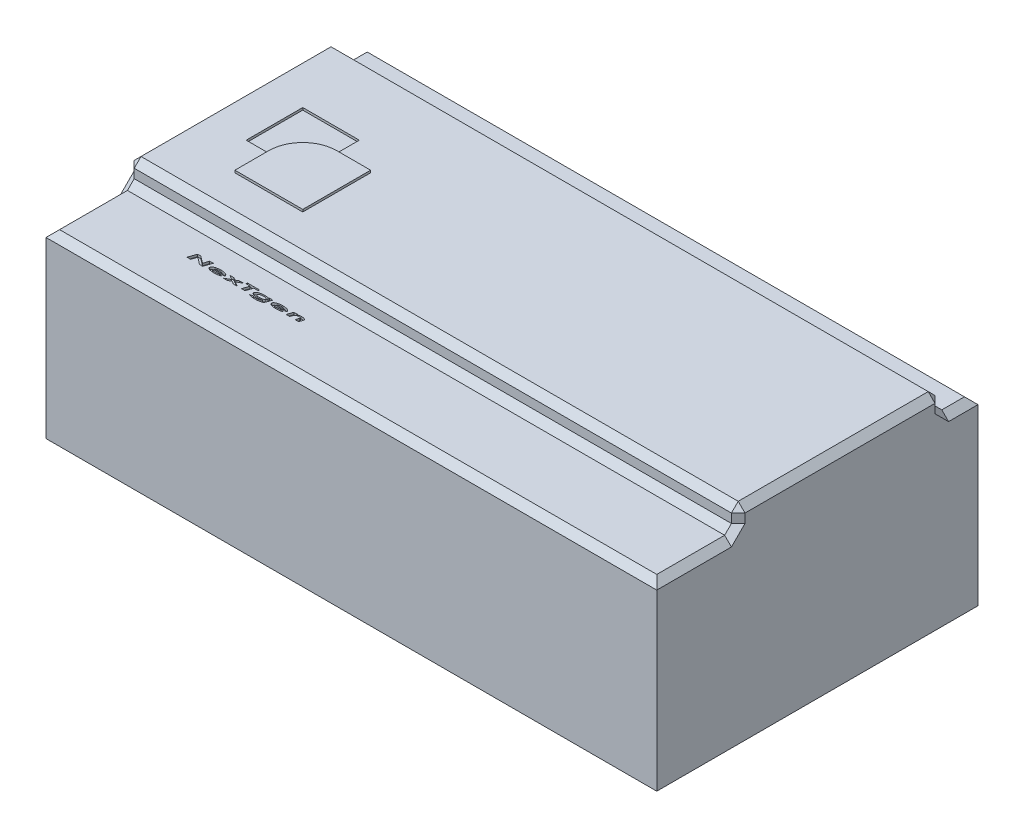
from build123d import *

# Parameters (mm, degrees)
SKETCH1_W           = 270
SKETCH1_H           = 142
BOSS_EXTRUDE1_DEPTH = 80
BOSS_EXTRUDE2_DEPTH = 10
SKETCH6_R           = 5
BOSS_EXTRUDE5_DEPTH = 2
CUT_EXTRUDE2_DEPTH  = 1
CHAMFER1_SIZE       = 3
SKETCH8_W           = 25
SKETCH8_H           = 25
CUT_EXTRUDE3_DEPTH  = 1
BOSS_EXTRUDE6_DEPTH = 1


with BuildPart() as part:
    # Sketch1 → Boss-Extrude1 (new body)
    with BuildSketch(Plane(origin=(0, 0, 0), x_dir=(1, 0, 0), z_dir=(0, 1, 0))):
        Rectangle(SKETCH1_W, SKETCH1_H)
    extrude(amount=BOSS_EXTRUDE1_DEPTH)

    # Sketch2 → Boss-Extrude2 (add)
    with BuildSketch(Plane(origin=(0, 80, 0), x_dir=(1, 0, 0), z_dir=(0, 1, 0))):
        Polygon((-135, -35), (135, -35), (135, 35), (135, 55), (-135, 55), (-135, 35), align=None)
    extrude(amount=BOSS_EXTRUDE2_DEPTH)

    # Sketch6 → Boss-Extrude5 (add)
    with BuildSketch(Plane.ZY.offset(135)):
        with Locations((-24.42759898, 39.904944775)):
            Circle(SKETCH6_R)
        with Locations((22.518514868, 39.904944775)):
            Circle(SKETCH6_R)
    extrude(amount=BOSS_EXTRUDE5_DEPTH)

    # Sketch7 → Cut-Extrude2 (cut)
    with BuildSketch(Plane(origin=(0, 80, 0), x_dir=(1, 0, 0), z_dir=(0, 1, 0))):
        Polygon((-92.091078078, -46.905996593), (-90.65798513, -46.905996593), (-87.531683046, -49.285603965), (-86.742921027, -46.905996593), (-85.158385771, -46.905996593), (-86.315937854, -50.405996593), (-87.740617341, -50.405996593), (-90.875332886, -48.000447715), (-91.672508367, -50.405996593), (-93.257043623, -50.405996593), align=None)
        with BuildLine():
            Line((-79.745024392, -49.649486176), (-78.369423431, -49.931337138))
            add(Edge.make_bspline(
                [(-78.369423431, -49.931337138), (-78.409202544, -49.951131626), (-78.490887738, -49.991779004), (-78.620489264, -50.046733239), (-78.75894812, -50.099611858), (-78.907502369, -50.147180504), (-79.064552353, -50.194069583), (-79.231507877, -50.236197272), (-79.407660389, -50.276513683), (-79.592715412, -50.312360782), (-79.784770026, -50.345544444), (-79.982868277, -50.373312761), (-80.186015616, -50.397118824), (-80.394537686, -50.416744416), (-80.608203023, -50.432036667), (-80.82698489, -50.44340482), (-81.050943252, -50.449643952), (-81.20195185, -50.450456935), (-81.278377758, -50.450868388)],
                knots=[0, 0, 0, 0, 0.000133268, 0.000273663, 0.00042211, 0.000577756, 0.000741483, 0.000913743, 0.001094206, 0.001283546, 0.00147915, 0.001678846, 0.001883564, 0.00209272, 0.002307118, 0.002526155, 0.002749902, 0.002979179, 0.002979179, 0.002979179, 0.002979179], degree=3))
            add(Edge.make_bspline(
                [(-81.278377758, -50.450868388), (-81.337974541, -50.450541944), (-81.455775772, -50.449896684), (-81.630148049, -50.4464952), (-81.799852761, -50.440287263), (-81.964609253, -50.430927446), (-82.124537545, -50.420104696), (-82.279450786, -50.405686254), (-82.429663821, -50.390281426), (-82.574858091, -50.369805897), (-82.715744677, -50.349449689), (-82.851792969, -50.325485108), (-82.9829899, -50.29900426), (-83.109133066, -50.269340976), (-83.230628496, -50.238119267), (-83.346948873, -50.203558169), (-83.458819882, -50.167185085), (-83.565539345, -50.128307741), (-83.666539882, -50.086553099), (-83.761802625, -50.044662502), (-83.849778325, -49.99905679), (-83.931726695, -49.953292951), (-84.007262531, -49.905525461), (-84.07588346, -49.855619582), (-84.138775404, -49.804765171), (-84.194142294, -49.751117885), (-84.243557252, -49.696636761), (-84.286035895, -49.640071345), (-84.321860751, -49.581808478), (-84.351436792, -49.521969514), (-84.375110615, -49.460620897), (-84.3908876, -49.397237088), (-84.401198288, -49.332213221), (-84.402579424, -49.288214283), (-84.403277597, -49.265972554)],
                knots=[0, 0, 0, 0, 0.000178792, 0.000353406, 0.000523195, 0.00068821, 0.000848459, 0.00100404, 0.001154945, 0.001301398, 0.001443885, 0.001581976, 0.001715765, 0.001845357, 0.001970687, 0.002092038, 0.002209327, 0.002323558, 0.002432665, 0.00253717, 0.00263563, 0.002729812, 0.0028187, 0.002903548, 0.002984253, 0.003061111, 0.003134592, 0.003204704, 0.003273005, 0.003339479, 0.003404717, 0.003469846, 0.003535092, 0.00360179, 0.00360179, 0.00360179, 0.00360179], degree=3))
            add(Edge.make_bspline(
                [(-84.403277597, -49.265972554), (-84.40238153, -49.240695045), (-84.400587942, -49.190099009), (-84.388772095, -49.114877496), (-84.367152557, -49.041520803), (-84.338179949, -48.969732725), (-84.301887572, -48.898998878), (-84.255312801, -48.831027039), (-84.202043311, -48.763667702), (-84.140905742, -48.697241528), (-84.070265228, -48.633893347), (-83.992010337, -48.571267628), (-83.906026442, -48.509718211), (-83.81154152, -48.450072916), (-83.708982427, -48.391993516), (-83.598255738, -48.335061227), (-83.478717848, -48.280966525), (-83.30829265, -48.208018171), (-83.082466629, -48.125192798), (-82.798958296, -48.038984708), (-82.501796204, -47.96652388), (-82.191435237, -47.905881053), (-81.867250401, -47.860106092), (-81.52943408, -47.827711331), (-81.178155548, -47.806504472), (-80.939300047, -47.804468596), (-80.817740739, -47.80343249)],
                knots=[0, 0, 0, 0, 7.5838e-05, 0.000151799, 0.000227689, 0.000304764, 0.000383789, 0.000465655, 0.000551502, 0.000641303, 0.0007361, 0.000835852, 0.000941888, 0.001053146, 0.001170894, 0.001295381, 0.001426518, 0.001564428, 0.001851477, 0.002147567, 0.002452974, 0.002768681, 0.003095888, 0.003434733, 0.003786583, 0.004151221, 0.004151221, 0.004151221, 0.004151221], degree=3))
            add(Edge.make_bspline(
                [(-80.817740739, -47.80343249), (-80.744119479, -47.804096089), (-80.598948014, -47.805404617), (-80.384300342, -47.812019237), (-80.175830572, -47.825170262), (-79.973278306, -47.841349902), (-79.776906864, -47.863948714), (-79.586896696, -47.891463782), (-79.402701703, -47.922514029), (-79.225362259, -47.959927616), (-79.055334137, -48.000559499), (-78.894501057, -48.04703577), (-78.742734827, -48.097628342), (-78.599779885, -48.151497017), (-78.466737317, -48.211783907), (-78.342282109, -48.275150843), (-78.227247441, -48.34375806), (-78.122270624, -48.416624599), (-78.027467162, -48.49162328), (-77.945418772, -48.569559534), (-77.8749076, -48.648252817), (-77.817514929, -48.729297318), (-77.772840372, -48.812416707), (-77.740967263, -48.897254878), (-77.721025154, -48.983666422), (-77.718593124, -49.041978068), (-77.717380162, -49.071060695)],
                knots=[0, 0, 0, 0, 0.000220871, 0.000435529, 0.000644144, 0.000847466, 0.001045058, 0.001237019, 0.001423403, 0.001605324, 0.001780646, 0.001947738, 0.002107372, 0.0022605, 0.002405796, 0.002545335, 0.002679284, 0.002807258, 0.002928471, 0.003041545, 0.00314635, 0.003244972, 0.003338758, 0.003428613, 0.00351622, 0.003603388, 0.003603388, 0.003603388, 0.003603388], degree=3))
            add(Edge.make_bspline(
                [(-77.717380162, -49.071060695), (-77.718046964, -49.090279235), (-77.719439743, -49.13042182), (-77.732013048, -49.19270385), (-77.749708112, -49.259980105), (-77.767165868, -49.305384124), (-77.776274392, -49.329073516)],
                knots=[0, 0, 0, 0, 5.7599e-05, 0.000120309, 0.000190042, 0.000266116, 0.000266116, 0.000266116, 0.000266116], degree=3))
            Line((-77.776274392, -49.329073516), (-82.877636572, -49.329073516))
            add(Edge.make_bspline(
                [(-82.877636572, -49.329073516), (-82.874506134, -49.349386996), (-82.868238749, -49.390056205), (-82.84323482, -49.448128194), (-82.805681881, -49.501989653), (-82.756431297, -49.552734561), (-82.695248039, -49.600584324), (-82.621943292, -49.645137465), (-82.536444276, -49.686512582), (-82.439105923, -49.723595655), (-82.331337612, -49.758113131), (-82.21314915, -49.78701312), (-82.085249847, -49.812505489), (-81.947556679, -49.832114438), (-81.800287888, -49.848621049), (-81.643317564, -49.859221372), (-81.476399512, -49.866635088), (-81.361820272, -49.867229485), (-81.302917021, -49.867535054)],
                knots=[0, 0, 0, 0, 6.1463e-05, 0.000123054, 0.000187618, 0.000257538, 0.000334406, 0.000420023, 0.000514406, 0.000618958, 0.000732265, 0.000853678, 0.000983755, 0.001123364, 0.001270784, 0.001428235, 0.001595249, 0.001771944, 0.001771944, 0.001771944, 0.001771944], degree=3))
            add(Edge.make_bspline(
                [(-81.302917021, -49.867535054), (-81.23069267, -49.86679523), (-81.088280467, -49.865336442), (-80.877761485, -49.855781182), (-80.673656764, -49.837971793), (-80.475826224, -49.814184307), (-80.283858588, -49.784521871), (-80.098533327, -49.746285123), (-79.918868186, -49.702718572), (-79.802591951, -49.667113835), (-79.745024392, -49.649486176)],
                knots=[0, 0, 0, 0, 0.000216675, 0.00042724, 0.000632018, 0.000831167, 0.001024933, 0.001214548, 0.00139871, 0.001579292, 0.001579292, 0.001579292, 0.001579292], degree=3))
        make_face()
        with BuildLine():
            add(Edge.make_bspline(
                [(-79.377636572, -48.880355567), (-79.392871526, -48.860365347), (-79.423847673, -48.819720655), (-79.479035494, -48.76458292), (-79.541419528, -48.713322198), (-79.610038836, -48.664803149), (-79.686249908, -48.620399708), (-79.770191003, -48.581038092), (-79.860645491, -48.543311617), (-79.958657787, -48.51121915), (-80.062385162, -48.481446493), (-80.172032621, -48.456617795), (-80.286798978, -48.434699041), (-80.40687022, -48.417552109), (-80.531922636, -48.403284099), (-80.66243123, -48.393640662), (-80.798294423, -48.388113117), (-80.890652303, -48.387220087), (-80.937632565, -48.386765824)],
                knots=[0, 0, 0, 0, 7.5334e-05, 0.000153171, 0.000233335, 0.000317368, 0.00040503, 0.000497541, 0.000595322, 0.000698863, 0.000806726, 0.000918976, 0.001035996, 0.001157162, 0.001282747, 0.001413525, 0.001549658, 0.001690599, 0.001690599, 0.001690599, 0.001690599], degree=3))
            add(Edge.make_bspline(
                [(-80.937632565, -48.386765824), (-80.98437682, -48.387252557), (-81.076963429, -48.388216634), (-81.214041412, -48.393381602), (-81.34771165, -48.404474026), (-81.477810784, -48.417925016), (-81.604441559, -48.436675119), (-81.727903272, -48.45772379), (-81.847686502, -48.484875863), (-81.963572236, -48.514548201), (-82.074278557, -48.54808118), (-82.178697153, -48.585096345), (-82.276293064, -48.625378143), (-82.36642828, -48.670287791), (-82.450673891, -48.716440536), (-82.527389782, -48.767308396), (-82.597479593, -48.821221259), (-82.63956042, -48.860839973), (-82.660288815, -48.880355567)],
                knots=[0, 0, 0, 0, 0.00014024, 0.000277774, 0.000411402, 0.000542562, 0.000670074, 0.000795371, 0.000918188, 0.001038415, 0.001154192, 0.001265071, 0.001370671, 0.001470695, 0.001567056, 0.001658645, 0.001746579, 0.001831944, 0.001831944, 0.001831944, 0.001831944], degree=3))
            Line((-82.660288815, -48.880355567), (-79.377636572, -48.880355567))
        make_face(mode=Mode.SUBTRACT)
        Polygon((-76.779980322, -47.848304285), (-75.038393783, -47.848304285), (-73.932724713, -48.568356368), (-72.606903399, -47.848304285), (-70.762251956, -47.848304285), (-73.093481924, -49.113829125), (-71.108606123, -50.405996593), (-72.84949154, -50.405996593), (-74.042800835, -49.629153644), (-75.473790418, -50.405996593), (-77.31844186, -50.405996593), (-74.882043623, -49.083680888), align=None)
        Polygon((-69.954559649, -46.905996593), (-64.659687854, -46.905996593), (-64.847588495, -47.489329926), (-66.653678239, -47.489329926), (-67.60720388, -50.405996593), (-69.191739136, -50.405996593), (-68.238914617, -47.489329926), (-70.15437936, -47.489329926), align=None)
        with BuildLine():
            Line((-59.448950674, -47.848304285), (-57.863013174, -47.848304285))
            Line((-57.863013174, -47.848304285), (-58.564836091, -49.933440503))
            add(Edge.make_bspline(
                [(-58.564836091, -49.933440503), (-58.582062239, -49.980296752), (-58.615163506, -50.070334361), (-58.667739527, -50.198387651), (-58.7209128, -50.313894578), (-58.773837411, -50.417825099), (-58.828541197, -50.50856022), (-58.882247707, -50.587858676), (-58.936696899, -50.654877461), (-58.976456649, -50.691976678), (-58.995324873, -50.70958233)],
                knots=[0, 0, 0, 0, 0.00014976, 0.000287774, 0.000415141, 0.000531165, 0.000637459, 0.000732752, 0.000818392, 0.000895738, 0.000895738, 0.000895738, 0.000895738], degree=3))
            add(Edge.make_bspline(
                [(-58.995324873, -50.70958233), (-59.026190033, -50.734282107), (-59.090544672, -50.785781767), (-59.20056253, -50.85361472), (-59.324382696, -50.919733452), (-59.463199005, -50.982274817), (-59.616679924, -51.042041663), (-59.784974536, -51.097437566), (-59.967824607, -51.150801183), (-60.16483379, -51.201128401), (-60.375913702, -51.246832729), (-60.600553365, -51.285593871), (-60.838081582, -51.319274294), (-61.088756315, -51.346474129), (-61.35251813, -51.367133394), (-61.629288064, -51.382563555), (-61.919172683, -51.39179648), (-62.1167123, -51.39270944), (-62.217680642, -51.39317608)],
                knots=[0, 0, 0, 0, 0.000118498, 0.000247071, 0.000386966, 0.000539456, 0.000703508, 0.000880879, 0.001070799, 0.001274858, 0.00149076, 0.001718529, 0.00195858, 0.00221037, 0.002474829, 0.002752201, 0.003041908, 0.003344806, 0.003344806, 0.003344806, 0.003344806], degree=3))
            add(Edge.make_bspline(
                [(-62.217680642, -51.39317608), (-62.302056621, -51.392924202), (-62.467807923, -51.392429405), (-62.712292342, -51.384023686), (-62.948420117, -51.372599243), (-63.176579365, -51.355683872), (-63.396375246, -51.334275425), (-63.60786927, -51.307248767), (-63.811236682, -51.277123167), (-64.005374699, -51.240383459), (-64.189359642, -51.200608561), (-64.362105949, -51.158254579), (-64.522385706, -51.11188104), (-64.671000989, -51.063583637), (-64.807621438, -51.012885835), (-64.932080727, -50.958746403), (-65.044941159, -50.902627388), (-65.11382081, -50.860340528), (-65.146967501, -50.839990984)],
                knots=[0, 0, 0, 0, 0.000253114, 0.000497226, 0.000733804, 0.000962289, 0.001183512, 0.001396225, 0.001601877, 0.001800169, 0.001988845, 0.002166545, 0.002333637, 0.002489283, 0.002635268, 0.002770601, 0.002896336, 0.003012971, 0.003012971, 0.003012971, 0.003012971], degree=3))
            Line((-65.146967501, -50.839990984), (-63.778377758, -50.560944509))
            add(Edge.make_bspline(
                [(-63.778377758, -50.560944509), (-63.725334029, -50.581048825), (-63.616674882, -50.622232164), (-63.444958711, -50.671868416), (-63.261992179, -50.714843785), (-63.067434556, -50.749383), (-62.861110055, -50.776714848), (-62.643344528, -50.796210764), (-62.413874568, -50.807172983), (-62.257188613, -50.808939074), (-62.177015578, -50.809842747)],
                knots=[0, 0, 0, 0, 0.000170119, 0.000348485, 0.000535726, 0.000733766, 0.000941006, 0.001159937, 0.001389478, 0.00163, 0.00163, 0.00163, 0.00163], degree=3))
            add(Edge.make_bspline(
                [(-62.177015578, -50.809842747), (-62.130038622, -50.809518572), (-62.037707912, -50.808881424), (-61.901654524, -50.805495714), (-61.770270034, -50.799255349), (-61.643831678, -50.790006526), (-61.522224458, -50.779044799), (-61.405555385, -50.765001804), (-61.293831738, -50.748195541), (-61.18698368, -50.72927888), (-61.085488607, -50.70834762), (-60.989537408, -50.685474065), (-60.899433553, -50.659877713), (-60.8149221, -50.633549186), (-60.736125352, -50.605750052), (-60.663442401, -50.575322093), (-60.59644493, -50.543382249), (-60.534705451, -50.509490393), (-60.477618872, -50.473011525), (-60.426038532, -50.431298587), (-60.377662564, -50.386335159), (-60.334424536, -50.336590784), (-60.295665369, -50.282602747), (-60.260362223, -50.225264008), (-60.23010177, -50.1631653), (-60.21375887, -50.119614862), (-60.205461091, -50.097503003)],
                knots=[0, 0, 0, 0, 0.000140932, 0.000276995, 0.000408257, 0.000535487, 0.000657298, 0.000774526, 0.000887961, 0.0009962, 0.001100015, 0.001198816, 0.001292042, 0.001380963, 0.001464346, 0.001542602, 0.001617238, 0.001686903, 0.001753801, 0.001820156, 0.001885627, 0.001951715, 0.00201749, 0.002084827, 0.002153498, 0.002224325, 0.002224325, 0.002224325, 0.002224325], degree=3))
            add(Edge.make_bspline(
                [(-60.205461091, -50.097503003), (-60.278599581, -50.122367272), (-60.426316056, -50.172585183), (-60.654611684, -50.233961272), (-60.889568182, -50.287624643), (-61.131975125, -50.330949144), (-61.381579719, -50.364570221), (-61.638440148, -50.387927264), (-61.902455059, -50.403329496), (-62.080939815, -50.405099466), (-62.171406604, -50.405996593)],
                knots=[0, 0, 0, 0, 0.000231694, 0.000467948, 0.000708792, 0.000954554, 0.001206412, 0.001464128, 0.00172816, 0.001999539, 0.001999539, 0.001999539, 0.001999539], degree=3))
            add(Edge.make_bspline(
                [(-62.171406604, -50.405996593), (-62.234514281, -50.405651533), (-62.359601234, -50.404967584), (-62.545466858, -50.397710893), (-62.72760864, -50.385997787), (-62.906186777, -50.36892695), (-63.081057683, -50.347959579), (-63.252595777, -50.32316811), (-63.420084022, -50.291842429), (-63.58338146, -50.257248001), (-63.740424262, -50.218417794), (-63.889447097, -50.174966568), (-64.029721727, -50.127249456), (-64.161718901, -50.076171389), (-64.285170505, -50.021710652), (-64.40000789, -49.963455354), (-64.506110128, -49.901301735), (-64.602682556, -49.8347323), (-64.689481335, -49.765975949), (-64.765187679, -49.694833748), (-64.829692049, -49.621998697), (-64.881771697, -49.546481303), (-64.923459076, -49.469661375), (-64.952157649, -49.390233771), (-64.970795591, -49.308904543), (-64.972790494, -49.253686211), (-64.973790418, -49.226008612)],
                knots=[0, 0, 0, 0, 0.000189315, 0.000375244, 0.000557925, 0.000736803, 0.000913341, 0.001086267, 0.001256651, 0.001424417, 0.001586982, 0.001741846, 0.001889954, 0.002031353, 0.002166325, 0.002294571, 0.002417462, 0.002534926, 0.002646175, 0.002749338, 0.002846227, 0.00293744, 0.003024008, 0.00310763, 0.003190142, 0.003273065, 0.003273065, 0.003273065, 0.003273065], degree=3))
            add(Edge.make_bspline(
                [(-64.973790418, -49.226008612), (-64.972237168, -49.19479739), (-64.969114399, -49.132048072), (-64.945594311, -49.038956569), (-64.906979988, -48.947871883), (-64.853899378, -48.858099292), (-64.784483659, -48.770815916), (-64.700886876, -48.684632252), (-64.601613129, -48.600640372), (-64.489071672, -48.517560975), (-64.363363826, -48.437295933), (-64.225316848, -48.362167371), (-64.077403848, -48.289381056), (-63.917726388, -48.222880066), (-63.748039744, -48.158522162), (-63.566930113, -48.100235253), (-63.375214048, -48.045395216), (-63.173992313, -47.995644111), (-62.966221114, -47.950128562), (-62.754589888, -47.910942216), (-62.540365862, -47.878152794), (-62.324148119, -47.850640368), (-62.105500866, -47.829807823), (-61.88482965, -47.814273794), (-61.661540248, -47.804885426), (-61.51189359, -47.803918694), (-61.436630963, -47.80343249)],
                knots=[0, 0, 0, 0, 9.3568e-05, 0.000188115, 0.000286164, 0.000389575, 0.000499954, 0.000619946, 0.000749227, 0.000889595, 0.001039354, 0.001196255, 0.001360877, 0.001533679, 0.00171495, 0.001905185, 0.002104251, 0.002313069, 0.002526915, 0.002742264, 0.00295863, 0.003176995, 0.003396056, 0.003617448, 0.003840591, 0.004066369, 0.004066369, 0.004066369, 0.004066369], degree=3))
            add(Edge.make_bspline(
                [(-61.436630963, -47.80343249), (-61.347334261, -47.804556474), (-61.172564307, -47.806756315), (-60.916737957, -47.822541022), (-60.673698373, -47.850884579), (-60.441452097, -47.888881065), (-60.21667188, -47.94157417), (-59.995705176, -48.008082133), (-59.776884439, -48.090050026), (-59.634819745, -48.155878562), (-59.563233527, -48.189049477)],
                knots=[0, 0, 0, 0, 0.000267887, 0.000524304, 0.000768508, 0.001001687, 0.001229918, 0.001460596, 0.001693565, 0.001930196, 0.001930196, 0.001930196, 0.001930196], degree=3))
            Line((-59.563233527, -48.189049477), (-59.448950674, -47.848304285))
        make_face()
        with BuildLine():
            add(Edge.make_bspline(
                [(-61.360208687, -48.386765824), (-61.430571603, -48.387341991), (-61.56858639, -48.388472127), (-61.771340256, -48.400193392), (-61.965774862, -48.417940396), (-62.151801721, -48.443799269), (-62.329149994, -48.477352851), (-62.498077632, -48.518141546), (-62.658850898, -48.565450174), (-62.809669067, -48.620227858), (-62.947007831, -48.68024145), (-63.068201363, -48.743608852), (-63.170346378, -48.811396661), (-63.254588691, -48.882354119), (-63.320665347, -48.957160363), (-63.367787328, -49.035952622), (-63.398321909, -49.118666264), (-63.40162598, -49.175742794), (-63.403277597, -49.204273836)],
                knots=[0, 0, 0, 0, 0.000211067, 0.000414001, 0.000609066, 0.000796665, 0.000977213, 0.001150326, 0.001317812, 0.001479724, 0.001631357, 0.001767168, 0.001889481, 0.001998381, 0.002096788, 0.002187331, 0.002272698, 0.002358022, 0.002358022, 0.002358022, 0.002358022], degree=3))
            add(Edge.make_bspline(
                [(-63.403277597, -49.204273836), (-63.401933155, -49.227339455), (-63.399272199, -49.27299152), (-63.377544848, -49.33933468), (-63.34277202, -49.401868118), (-63.292715238, -49.459685031), (-63.230338402, -49.514735008), (-63.153997348, -49.565664835), (-63.063835114, -49.612333685), (-62.961500732, -49.656137792), (-62.847216114, -49.694906025), (-62.723083521, -49.729014629), (-62.589735054, -49.758471343), (-62.447197303, -49.782144572), (-62.295553023, -49.799990962), (-62.134684207, -49.81343097), (-61.964413944, -49.820940967), (-61.847729078, -49.822079446), (-61.787892982, -49.822663259)],
                knots=[0, 0, 0, 0, 6.9067e-05, 0.000136699, 0.000207317, 0.000282455, 0.000364902, 0.000456298, 0.000556972, 0.000669103, 0.000789943, 0.000918709, 0.001055138, 0.001199448, 0.001351983, 0.001513092, 0.001683639, 0.001863148, 0.001863148, 0.001863148, 0.001863148], degree=3))
            add(Edge.make_bspline(
                [(-61.787892982, -49.822663259), (-61.69741367, -49.821505602), (-61.519989904, -49.819235514), (-61.259051343, -49.799808546), (-61.008581345, -49.768648776), (-60.807311204, -49.731785059), (-60.653652249, -49.696218695), (-60.545377586, -49.666703821), (-60.443098636, -49.634634456), (-60.346858757, -49.599723294), (-60.257196463, -49.561655848), (-60.173120026, -49.522172681), (-60.096168233, -49.47813035), (-60.024597375, -49.433408955), (-59.961105327, -49.385458539), (-59.904377423, -49.337693677), (-59.857320889, -49.287505225), (-59.818034795, -49.237194882), (-59.788467473, -49.185246035), (-59.765915023, -49.133075132), (-59.752951932, -49.079167718), (-59.751269537, -49.042845939), (-59.750433046, -49.024786657)],
                knots=[0, 0, 0, 0, 0.000271407, 0.000532212, 0.000784493, 0.001028311, 0.001145658, 0.001257574, 0.001364899, 0.00146715, 0.001564553, 0.001657063, 0.001745594, 0.001830395, 0.001910042, 0.001984113, 0.002052557, 0.002116082, 0.00217513, 0.002231382, 0.002286141, 0.002340291, 0.002340291, 0.002340291, 0.002340291], degree=3))
            add(Edge.make_bspline(
                [(-59.750433046, -49.024786657), (-59.751750066, -49.002180271), (-59.754374528, -48.957131894), (-59.776964647, -48.891366365), (-59.813428707, -48.829440765), (-59.863756779, -48.770241368), (-59.928522671, -48.71533325), (-60.006501598, -48.662377026), (-60.098907622, -48.613143693), (-60.204183713, -48.56670112), (-60.320419387, -48.524549883), (-60.445352582, -48.487195453), (-60.578536647, -48.456909972), (-60.719242248, -48.430576491), (-60.868424897, -48.411640337), (-61.025279201, -48.3965743), (-61.190214943, -48.388359851), (-61.30270849, -48.387305002), (-61.360208687, -48.386765824)],
                knots=[0, 0, 0, 0, 6.7672e-05, 0.000134852, 0.000206163, 0.000282289, 0.000366779, 0.000460123, 0.000564593, 0.000680416, 0.00080507, 0.000935284, 0.00107134, 0.001214633, 0.001364561, 0.001522301, 0.00168728, 0.001859778, 0.001859778, 0.001859778, 0.001859778], degree=3))
        make_face(mode=Mode.SUBTRACT)
        with BuildLine():
            Line((-52.373229521, -49.649486176), (-50.997628559, -49.931337138))
            add(Edge.make_bspline(
                [(-50.997628559, -49.931337138), (-51.037407672, -49.951131626), (-51.119092866, -49.991779004), (-51.248694392, -50.046733239), (-51.387153248, -50.099611858), (-51.535707497, -50.147180504), (-51.692757481, -50.194069583), (-51.859713006, -50.236197272), (-52.035865517, -50.276513683), (-52.22092054, -50.312360782), (-52.412975154, -50.345544444), (-52.611073405, -50.373312761), (-52.814220744, -50.397118824), (-53.022742814, -50.416744416), (-53.236408151, -50.432036667), (-53.455190018, -50.44340482), (-53.67914838, -50.449643952), (-53.830156978, -50.450456935), (-53.906582886, -50.450868388)],
                knots=[0, 0, 0, 0, 0.000133268, 0.000273663, 0.00042211, 0.000577756, 0.000741483, 0.000913743, 0.001094206, 0.001283546, 0.00147915, 0.001678846, 0.001883564, 0.00209272, 0.002307118, 0.002526155, 0.002749902, 0.002979179, 0.002979179, 0.002979179, 0.002979179], degree=3))
            add(Edge.make_bspline(
                [(-53.906582886, -50.450868388), (-53.966179669, -50.450541944), (-54.0839809, -50.449896684), (-54.258353177, -50.4464952), (-54.428057889, -50.440287263), (-54.592814381, -50.430927446), (-54.752742674, -50.420104696), (-54.907655914, -50.405686254), (-55.057868949, -50.390281426), (-55.203063219, -50.369805897), (-55.343949805, -50.349449689), (-55.479998097, -50.325485108), (-55.611195028, -50.29900426), (-55.737338194, -50.269340976), (-55.858833624, -50.238119267), (-55.975154002, -50.203558169), (-56.087025011, -50.167185085), (-56.193744474, -50.128307741), (-56.294745011, -50.086553099), (-56.390007753, -50.044662502), (-56.477983453, -49.99905679), (-56.559931823, -49.953292951), (-56.63546766, -49.905525461), (-56.704088588, -49.855619582), (-56.766980532, -49.804765171), (-56.822347422, -49.751117885), (-56.87176238, -49.696636761), (-56.914241024, -49.640071345), (-56.950065879, -49.581808478), (-56.97964192, -49.521969514), (-57.003315743, -49.460620897), (-57.019092728, -49.397237088), (-57.029403416, -49.332213221), (-57.030784553, -49.288214283), (-57.031482726, -49.265972554)],
                knots=[0, 0, 0, 0, 0.000178792, 0.000353406, 0.000523195, 0.00068821, 0.000848459, 0.00100404, 0.001154945, 0.001301398, 0.001443885, 0.001581976, 0.001715765, 0.001845357, 0.001970687, 0.002092038, 0.002209327, 0.002323558, 0.002432665, 0.00253717, 0.00263563, 0.002729812, 0.0028187, 0.002903548, 0.002984253, 0.003061111, 0.003134592, 0.003204704, 0.003273005, 0.003339479, 0.003404717, 0.003469846, 0.003535092, 0.00360179, 0.00360179, 0.00360179, 0.00360179], degree=3))
            add(Edge.make_bspline(
                [(-57.031482726, -49.265972554), (-57.030586659, -49.240695045), (-57.028793071, -49.190099009), (-57.016977224, -49.114877496), (-56.995357685, -49.041520803), (-56.966385077, -48.969732725), (-56.9300927, -48.898998878), (-56.883517929, -48.831027039), (-56.830248439, -48.763667702), (-56.76911087, -48.697241528), (-56.698470356, -48.633893347), (-56.620215466, -48.571267628), (-56.53423157, -48.509718211), (-56.439746648, -48.450072916), (-56.337187555, -48.391993516), (-56.226460866, -48.335061227), (-56.106922976, -48.280966525), (-55.936497779, -48.208018171), (-55.710671757, -48.125192798), (-55.427163424, -48.038984708), (-55.130001332, -47.96652388), (-54.819640365, -47.905881053), (-54.495455529, -47.860106092), (-54.157639208, -47.827711331), (-53.806360676, -47.806504472), (-53.567505175, -47.804468596), (-53.445945867, -47.80343249)],
                knots=[0, 0, 0, 0, 7.5838e-05, 0.000151799, 0.000227689, 0.000304764, 0.000383789, 0.000465655, 0.000551502, 0.000641303, 0.0007361, 0.000835852, 0.000941888, 0.001053146, 0.001170894, 0.001295381, 0.001426518, 0.001564428, 0.001851477, 0.002147567, 0.002452974, 0.002768681, 0.003095888, 0.003434733, 0.003786583, 0.004151221, 0.004151221, 0.004151221, 0.004151221], degree=3))
            add(Edge.make_bspline(
                [(-53.445945867, -47.80343249), (-53.372324607, -47.804096089), (-53.227153142, -47.805404617), (-53.01250547, -47.812019237), (-52.8040357, -47.825170262), (-52.601483435, -47.841349902), (-52.405111992, -47.863948714), (-52.215101824, -47.891463782), (-52.030906831, -47.922514029), (-51.853567387, -47.959927616), (-51.683539265, -48.000559499), (-51.522706185, -48.04703577), (-51.370939955, -48.097628342), (-51.227985013, -48.151497017), (-51.094942445, -48.211783907), (-50.970487237, -48.275150843), (-50.855452569, -48.34375806), (-50.750475752, -48.416624599), (-50.65567229, -48.49162328), (-50.573623901, -48.569559534), (-50.503112728, -48.648252817), (-50.445720057, -48.729297318), (-50.4010455, -48.812416707), (-50.369172391, -48.897254878), (-50.349230282, -48.983666422), (-50.346798252, -49.041978068), (-50.34558529, -49.071060695)],
                knots=[0, 0, 0, 0, 0.000220871, 0.000435529, 0.000644144, 0.000847466, 0.001045058, 0.001237019, 0.001423403, 0.001605324, 0.001780646, 0.001947738, 0.002107372, 0.0022605, 0.002405796, 0.002545335, 0.002679284, 0.002807258, 0.002928471, 0.003041545, 0.00314635, 0.003244972, 0.003338758, 0.003428613, 0.00351622, 0.003603388, 0.003603388, 0.003603388, 0.003603388], degree=3))
            add(Edge.make_bspline(
                [(-50.34558529, -49.071060695), (-50.346252092, -49.090279235), (-50.347644871, -49.13042182), (-50.360218176, -49.19270385), (-50.37791324, -49.259980105), (-50.395370996, -49.305384124), (-50.404479521, -49.329073516)],
                knots=[0, 0, 0, 0, 5.7599e-05, 0.000120309, 0.000190042, 0.000266116, 0.000266116, 0.000266116, 0.000266116], degree=3))
            Line((-50.404479521, -49.329073516), (-55.5058417, -49.329073516))
            add(Edge.make_bspline(
                [(-55.5058417, -49.329073516), (-55.502711263, -49.349386996), (-55.496443877, -49.390056205), (-55.471439948, -49.448128194), (-55.433887009, -49.501989653), (-55.384636425, -49.552734561), (-55.323453167, -49.600584324), (-55.25014842, -49.645137465), (-55.164649405, -49.686512582), (-55.067311052, -49.723595655), (-54.95954274, -49.758113131), (-54.841354278, -49.78701312), (-54.713454975, -49.812505489), (-54.575761807, -49.832114438), (-54.428493016, -49.848621049), (-54.271522693, -49.859221372), (-54.10460464, -49.866635088), (-53.9900254, -49.867229485), (-53.931122149, -49.867535054)],
                knots=[0, 0, 0, 0, 6.1463e-05, 0.000123054, 0.000187618, 0.000257538, 0.000334406, 0.000420023, 0.000514406, 0.000618958, 0.000732265, 0.000853678, 0.000983755, 0.001123364, 0.001270784, 0.001428235, 0.001595249, 0.001771944, 0.001771944, 0.001771944, 0.001771944], degree=3))
            add(Edge.make_bspline(
                [(-53.931122149, -49.867535054), (-53.858897798, -49.86679523), (-53.716485596, -49.865336442), (-53.505966613, -49.855781182), (-53.301861892, -49.837971793), (-53.104031352, -49.814184307), (-52.912063717, -49.784521871), (-52.726738455, -49.746285123), (-52.547073314, -49.702718572), (-52.430797079, -49.667113835), (-52.373229521, -49.649486176)],
                knots=[0, 0, 0, 0, 0.000216675, 0.00042724, 0.000632018, 0.000831167, 0.001024933, 0.001214548, 0.00139871, 0.001579292, 0.001579292, 0.001579292, 0.001579292], degree=3))
        make_face()
        with BuildLine():
            add(Edge.make_bspline(
                [(-52.0058417, -48.880355567), (-52.021076654, -48.860365347), (-52.052052801, -48.819720655), (-52.107240622, -48.76458292), (-52.169624656, -48.713322198), (-52.238243964, -48.664803149), (-52.314455036, -48.620399708), (-52.398396132, -48.581038092), (-52.488850619, -48.543311617), (-52.586862915, -48.51121915), (-52.690590291, -48.481446493), (-52.800237749, -48.456617795), (-52.915004106, -48.434699041), (-53.035075348, -48.417552109), (-53.160127764, -48.403284099), (-53.290636358, -48.393640662), (-53.426499551, -48.388113117), (-53.518857431, -48.387220087), (-53.565837694, -48.386765824)],
                knots=[0, 0, 0, 0, 7.5334e-05, 0.000153171, 0.000233335, 0.000317368, 0.00040503, 0.000497541, 0.000595322, 0.000698863, 0.000806726, 0.000918976, 0.001035996, 0.001157162, 0.001282747, 0.001413525, 0.001549658, 0.001690599, 0.001690599, 0.001690599, 0.001690599], degree=3))
            add(Edge.make_bspline(
                [(-53.565837694, -48.386765824), (-53.612581948, -48.387252557), (-53.705168557, -48.388216634), (-53.84224654, -48.393381602), (-53.975916778, -48.404474026), (-54.106015913, -48.417925016), (-54.232646687, -48.436675119), (-54.3561084, -48.45772379), (-54.475891631, -48.484875863), (-54.591777364, -48.514548201), (-54.702483685, -48.54808118), (-54.806902281, -48.585096345), (-54.904498192, -48.625378143), (-54.994633408, -48.670287791), (-55.078879019, -48.716440536), (-55.155594911, -48.767308396), (-55.225684722, -48.821221259), (-55.267765548, -48.860839973), (-55.288493944, -48.880355567)],
                knots=[0, 0, 0, 0, 0.00014024, 0.000277774, 0.000411402, 0.000542562, 0.000670074, 0.000795371, 0.000918188, 0.001038415, 0.001154192, 0.001265071, 0.001370671, 0.001470695, 0.001567056, 0.001658645, 0.001746579, 0.001831944, 0.001831944, 0.001831944, 0.001831944], degree=3))
            Line((-55.288493944, -48.880355567), (-52.0058417, -48.880355567))
        make_face(mode=Mode.SUBTRACT)
        with BuildLine():
            Line((-48.590677437, -47.848304285), (-47.005441059, -47.848304285))
            Line((-47.005441059, -47.848304285), (-47.102195867, -48.135764221))
            add(Edge.make_bspline(
                [(-47.102195867, -48.135764221), (-47.026941852, -48.109113549), (-46.877019619, -48.056019661), (-46.648224424, -47.989119866), (-46.417688484, -47.931410154), (-46.184734485, -47.884195829), (-45.949256874, -47.848690451), (-45.711838497, -47.823011061), (-45.472106887, -47.805841449), (-45.311560318, -47.804238042), (-45.230901796, -47.80343249)],
                knots=[0, 0, 0, 0, 0.000239462, 0.000477059, 0.000714785, 0.00095225, 0.001189832, 0.001428924, 0.00166855, 0.001910486, 0.001910486, 0.001910486, 0.001910486], degree=3))
            add(Edge.make_bspline(
                [(-45.230901796, -47.80343249), (-45.163347238, -47.804119787), (-45.031203629, -47.80546421), (-44.837579201, -47.815539957), (-44.653198653, -47.831113422), (-44.478487335, -47.854382377), (-44.312965343, -47.883547478), (-44.156876871, -47.919911601), (-44.0100194, -47.962473689), (-43.873965476, -48.011175252), (-43.750535942, -48.064385842), (-43.642022924, -48.121432281), (-43.549898499, -48.182222808), (-43.474400796, -48.247010564), (-43.415074534, -48.315204675), (-43.372204242, -48.387369164), (-43.346448988, -48.463819917), (-43.343064012, -48.516289251), (-43.341378559, -48.542414862)],
                knots=[0, 0, 0, 0, 0.000202655, 0.000396413, 0.000581512, 0.000757618, 0.000924992, 0.001085537, 0.001238185, 0.001383446, 0.001518779, 0.001641104, 0.001750777, 0.001849184, 0.001938692, 0.002020702, 0.002099634, 0.002177912, 0.002177912, 0.002177912, 0.002177912], degree=3))
            add(Edge.make_bspline(
                [(-43.341378559, -48.542414862), (-43.341620442, -48.555751225), (-43.342131148, -48.583909366), (-43.347733375, -48.628316606), (-43.355206864, -48.677508671), (-43.36672142, -48.731210434), (-43.380879964, -48.789617908), (-43.397521645, -48.852627287), (-43.418050898, -48.920146335), (-43.433573481, -48.966398948), (-43.441638976, -48.990431689)],
                knots=[0, 0, 0, 0, 3.9989e-05, 8.4431e-05, 0.000134112, 0.000189251, 0.00024911, 0.000314416, 0.000384728, 0.000460776, 0.000460776, 0.000460776, 0.000460776], degree=3))
            Line((-43.441638976, -48.990431689), (-43.914896187, -50.405996593))
            Line((-43.914896187, -50.405996593), (-45.499431444, -50.405996593))
            Line((-45.499431444, -50.405996593), (-45.029679841, -48.998144029))
            add(Edge.make_bspline(
                [(-45.029679841, -48.998144029), (-45.019066933, -48.966222387), (-44.999365273, -48.906963485), (-44.976864838, -48.823748986), (-44.96193803, -48.753279261), (-44.95981511, -48.710270164), (-44.95886654, -48.691052683)],
                knots=[0, 0, 0, 0, 0.000100886, 0.000187283, 0.00025865, 0.000316296, 0.000316296, 0.000316296, 0.000316296], degree=3))
            add(Edge.make_bspline(
                [(-44.95886654, -48.691052683), (-44.959475731, -48.679037697), (-44.960671421, -48.655455301), (-44.97221567, -48.621585823), (-44.989063918, -48.589542516), (-45.013353267, -48.559753367), (-45.0452298, -48.533162204), (-45.083028689, -48.507658271), (-45.128548356, -48.485931202), (-45.179540354, -48.464517006), (-45.237235833, -48.446856688), (-45.300621634, -48.43063667), (-45.369648061, -48.416782976), (-45.444514689, -48.405497951), (-45.525036206, -48.397500289), (-45.611518045, -48.390953391), (-45.703667525, -48.387740355), (-45.76702452, -48.387096148), (-45.799511572, -48.386765824)],
                knots=[0, 0, 0, 0, 3.5929e-05, 7.0519e-05, 0.000106276, 0.000144163, 0.000184924, 0.000230427, 0.000280595, 0.000335931, 0.000396243, 0.000461372, 0.000532186, 0.000607346, 0.000688413, 0.000774882, 0.000867496, 0.000964962, 0.000964962, 0.000964962, 0.000964962], degree=3))
            add(Edge.make_bspline(
                [(-45.799511572, -48.386765824), (-45.864757048, -48.388258489), (-45.995301137, -48.391245037), (-46.191301979, -48.411030036), (-46.386866459, -48.446117679), (-46.548636056, -48.484560158), (-46.674719738, -48.521605145), (-46.763880879, -48.552437023), (-46.847500859, -48.585969535), (-46.9252938, -48.622547262), (-46.997868693, -48.660950442), (-47.064726402, -48.702296242), (-47.125622629, -48.746648178), (-47.182926648, -48.79355152), (-47.235660637, -48.848208631), (-47.28648546, -48.91210901), (-47.335900237, -48.986744445), (-47.384743361, -49.071542269), (-47.432691393, -49.166728216), (-47.478205553, -49.272686799), (-47.524409852, -49.388605207), (-47.552005567, -49.470323692), (-47.566338495, -49.512767426)],
                knots=[0, 0, 0, 0, 0.000195739, 0.000391637, 0.000590243, 0.000791418, 0.000890137, 0.000984372, 0.001074337, 0.001160278, 0.001242144, 0.001320551, 0.001395862, 0.001468037, 0.001542408, 0.001623217, 0.001712667, 0.001810676, 0.001916657, 0.002032198, 0.002156536, 0.002290906, 0.002290906, 0.002290906, 0.002290906], degree=3))
            Line((-47.566338495, -49.512767426), (-47.863614136, -50.405996593))
            Line((-47.863614136, -50.405996593), (-49.448149392, -50.405996593))
            Line((-49.448149392, -50.405996593), (-48.590677437, -47.848304285))
        make_face()
    extrude(amount=-CUT_EXTRUDE2_DEPTH, mode=Mode.SUBTRACT)

    # Chamfer1
    chamfer1_edges = [part.edges().sort_by_distance(p)[0] for p in [
        (-135, 80, -63),
        (135, 80, -63),
        (-135, 80, 53),
        (0, 80, -55),
        (0, 80, 71),
        (135, 85, -55),
        (-135, 85, -55),
        (0, 80, 35),
        (-135, 85, 35),
        (135, 85, 35),
        (135, 90, -10),
        (0, 90, -55),
        (-135, 90, -10),
        (0, 90, 35),
        (135, 80, 53),
        (0, 80, -71),
    ]]
    chamfer(chamfer1_edges, length=CHAMFER1_SIZE)

    # Sketch8 → Cut-Extrude3 (cut)
    with BuildSketch(Plane(origin=(0, 90, 0), x_dir=(1, 0, 0), z_dir=(0, 1, 0))):
        with Locations((-102.5, 10)):
            Rectangle(SKETCH8_W, SKETCH8_H)
    extrude(amount=-CUT_EXTRUDE3_DEPTH, mode=Mode.SUBTRACT)

    # Sketch9 → Boss-Extrude6 (add)
    with BuildSketch(Plane(origin=(0, 90, 0), x_dir=(1, 0, 0), z_dir=(0, 1, 0))):
        with BuildLine():
            Line((-90, 12.5), (-75, 12.5))
            Line((-75, 12.5), (-75, -17.5))
            Line((-75, -17.5), (-105, -17.5))
            Line((-105, -17.5), (-105, -2.5))
            ThreePointArc((-105, -2.5), (-100.606601718, 8.106601718), (-90, 12.5))
        make_face()
    extrude(amount=BOSS_EXTRUDE6_DEPTH)


solid = part.part
